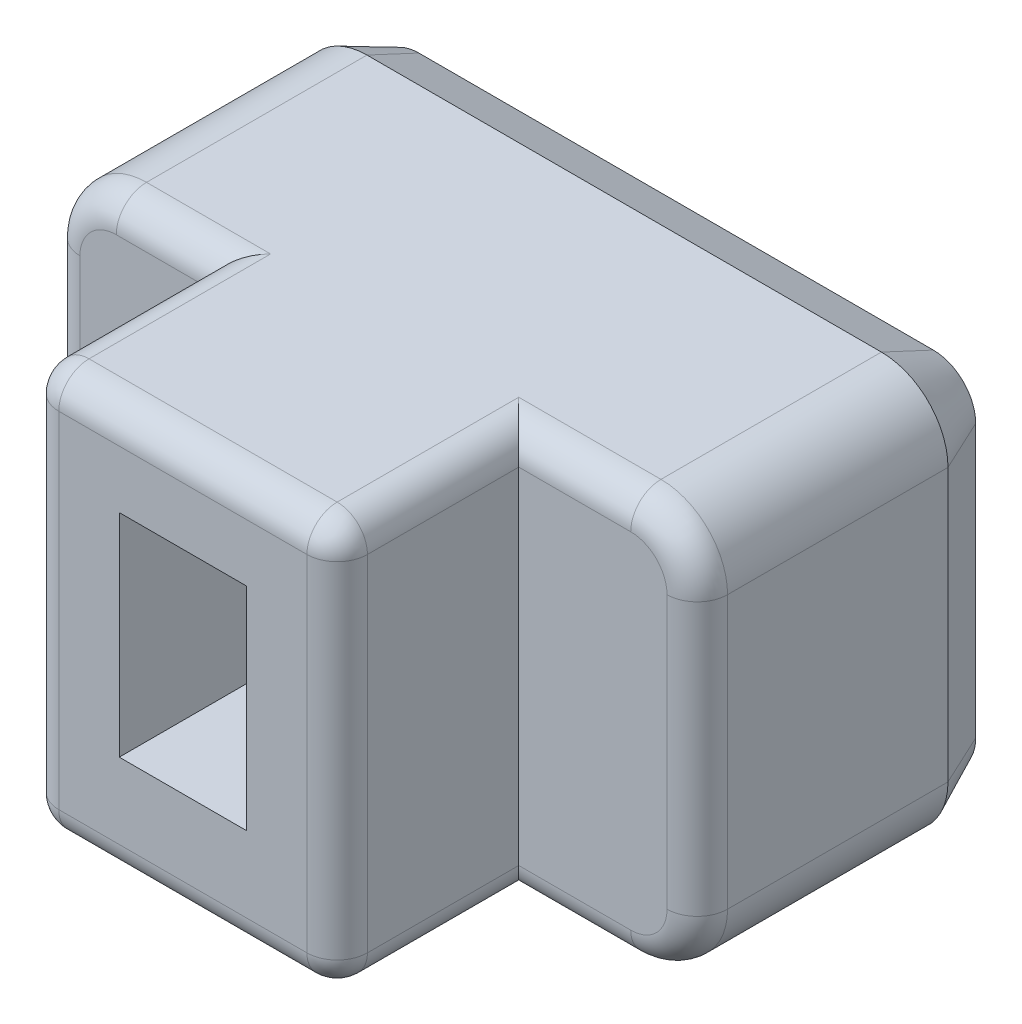
from build123d import *

# Parameters (mm, degrees)
BOSS_EXTRU_1_DEPTH      = 8
ESQUISSE3_W             = 2.1
ESQUISSE3_H             = 3.5
ENL_V_MAT_EXTRU_1_DEPTH = 3
ESQUISSE4_OUTSIDE_W     = 15.69
ESQUISSE4_OUTSIDE_H     = 11.69
ESQUISSE4_OUTSIDE_W_2   = 5.1
ESQUISSE4_OUTSIDE_H_2   = 6.7
ENL_V_MAT_EXTRU_2_DEPTH = 3
CONG_1_R                = 0.5
CHANFREIN1_SIZE         = 0.4
CHANFREIN1_SIZE2        = 0.857802768
ENL_V_MAT_EXTRU_3_DEPTH = 0.2
BOSS_EXTRU_2_DEPTH      = 0.2
BOSS_EXTRU_2_2_DEPTH    = 0.2
BOSS_EXTRU_2_3_DEPTH    = 0.2


with BuildPart() as part:
    # Esquisse2 → Boss.-Extru.1 (new body)
    with BuildSketch(Plane.XY):
        with BuildLine():
            Line((1.1, 0), (9.6, 0))
            ThreePointArc((9.6, 0), (10.377817459, 0.322182541), (10.7, 1.1))
            Line((10.7, 1.1), (10.7, 5.6))
            ThreePointArc((10.7, 5.6), (10.377817459, 6.377817459), (9.6, 6.7))
            Line((9.6, 6.7), (1.1, 6.7))
            ThreePointArc((1.1, 6.7), (0.322182541, 6.377817459), (0, 5.6))
            Line((0, 5.6), (0, 1.1))
            ThreePointArc((0, 1.1), (0.322182541, 0.322182541), (1.1, 0))
        make_face()
    extrude(amount=BOSS_EXTRU_1_DEPTH)

    # Esquisse3 → Enlèv. mat.-Extru.1 (cut)
    with BuildSketch(Plane.XY.offset(8)):
        with Locations((5.2, 3.5)):
            Rectangle(ESQUISSE3_W, ESQUISSE3_H)
    extrude(amount=-ENL_V_MAT_EXTRU_1_DEPTH, mode=Mode.SUBTRACT)

    # Esquisse4 outside → Enlèv. mat.-Extru.2 (cut)
    with BuildSketch(Plane.XY.offset(8)):
        with Locations((5.35, 3.35)):
            Rectangle(ESQUISSE4_OUTSIDE_W, ESQUISSE4_OUTSIDE_H)
        with Locations((5.2, 3.35)):
            Rectangle(ESQUISSE4_OUTSIDE_W_2, ESQUISSE4_OUTSIDE_H_2, mode=Mode.SUBTRACT)
    extrude(amount=-ENL_V_MAT_EXTRU_2_DEPTH, mode=Mode.SUBTRACT)

    # Congé1
    cong_1_edges = [part.edges().sort_by_distance(p)[0] for p in [
        (8.675, 0, 5),
        (10.377817459, 0.322182541, 5),
        (10.7, 3.35, 5),
        (10.377817459, 6.377817459, 5),
        (1.875, 6.7, 5),
        (0.322182541, 6.377817459, 5),
        (1.875, 0, 5),
        (0.322182541, 0.322182541, 5),
        (7.75, 6.7, 6.5),
        (2.65, 6.7, 6.5),
        (7.75, 0, 6.5),
        (2.65, 0, 6.5),
        (2.65, 3.35, 8),
        (5.2, 6.7, 8),
        (7.75, 3.35, 8),
        (5.2, 0, 8),
        (8.675, 6.7, 5),
        (0, 3.35, 5),
    ]]
    fillet(cong_1_edges, radius=CONG_1_R)

    # Chanfrein1
    chanfrein1_edges = [part.edges().sort_by_distance(p)[0] for p in [
        (5.35, 0, 0),
        (10.377817459, 0.322182541, 0),
        (0.322182541, 0.322182541, 0),
        (10.7, 3.35, 0),
        (0, 3.35, 0),
        (10.377817459, 6.377817459, 0),
        (0.322182541, 6.377817459, 0),
        (5.35, 6.7, 0),
    ]]
    chanfrein1_side = [part.faces().sort_by_distance(p)[0] for p in [
        (5.35, 3.35, 0),
    ]]
    chamfer(chanfrein1_edges, length=CHANFREIN1_SIZE, length2=CHANFREIN1_SIZE2, reference=chanfrein1_side[0])

    # Esquisse5 → Enlèv. mat.-Extru.3 (cut)
    with BuildSketch(Plane.XY):
        Polygon((2.11844453, 4.708587918), (3.713440101, 4.708587918), (3.713440101, 5.092998901), (1.739458701, 5.092998901), (1.739458701, 1.592998901), (3.627412643, 1.592998901), (3.627412643, 1.977409884), (2.11844453, 1.977409884), (2.11844453, 3.107392169), (3.46000786, 3.107392169), (3.46000786, 3.491803153), (2.11844453, 3.491803153), align=None)
        with BuildLine():
            add(Edge.make_bspline(
                [(5.687886514, 3.544504658), (5.783379122, 3.700654457), (5.975874702, 4.015423806), (6.160061615, 4.33512635), (6.252877656, 4.49623185)],
                knots=[0, 0, 0, 0, 0.992153778, 2, 2, 2, 2], degree=3))
            Line((6.252877656, 4.49623185), (6.266828055, 4.49623185))
            add(Edge.make_bspline(
                [(6.266828055, 4.49623185), (6.258108677, 4.324471085), (6.240506943, 3.977739075), (6.237911785, 3.630569277), (6.236602191, 3.455377112)],
                knots=[0, 0, 0, 0, 0.990740747, 2, 2, 2, 2], degree=3))
            Line((6.236602191, 3.455377112), (6.236602191, 1.592998901))
            Line((6.236602191, 1.592998901), (6.615588019, 1.592998901))
            Line((6.615588019, 1.592998901), (6.615588019, 5.092998901))
            Line((6.615588019, 5.092998901), (6.238927258, 5.092998901))
            Line((6.238927258, 5.092998901), (5.018267382, 3.141493144))
            add(Edge.make_bspline(
                [(5.018267382, 3.141493144), (4.966567896, 3.058224881), (4.865182286, 2.894931114), (4.721122886, 2.652016731), (4.583012533, 2.418899666), (4.495920572, 2.265082227), (4.453276239, 2.189765951)],
                knots=[0, 0, 0, 0, 1.062550423, 2.083721383, 3.06169958, 4, 4, 4, 4], degree=3))
            Line((4.453276239, 2.189765951), (4.439325841, 2.189765951))
            add(Edge.make_bspline(
                [(4.439325841, 2.189765951), (4.444061402, 2.27267783), (4.453926705, 2.445403045), (4.462318939, 2.714672702), (4.469221198, 3.004020303), (4.469439097, 3.20348993), (4.469551704, 3.30657286)],
                knots=[0, 0, 0, 0, 0.891833965, 1.85790283, 2.892996115, 4, 4, 4, 4], degree=3))
            Line((4.469551704, 3.30657286), (4.469551704, 5.092998901))
            Line((4.469551704, 5.092998901), (4.090565876, 5.092998901))
            Line((4.090565876, 5.092998901), (4.090565876, 1.592998901))
            Line((4.090565876, 1.592998901), (4.467226638, 1.592998901))
            Line((4.467226638, 1.592998901), (5.687886514, 3.544504658))
        make_face()
        Polygon((8.252124778, 5.092998901), (7.873138949, 5.092998901), (7.873138949, 1.977409884), (6.833834255, 1.977409884), (6.833834255, 1.592998901), (9.291429472, 1.592998901), (9.291429472, 1.977409884), (8.252124778, 1.977409884), align=None)
    extrude(amount=ENL_V_MAT_EXTRU_3_DEPTH, mode=Mode.SUBTRACT)


with BuildPart() as body_2:
    # Esquisse5_4 → Boss.-Extru.2 (new body)
    with BuildSketch(Plane.XY):
        Polygon((2.11844453, 4.708587918), (3.713440101, 4.708587918), (3.713440101, 5.092998901), (1.739458701, 5.092998901), (1.739458701, 1.592998901), (3.627412643, 1.592998901), (3.627412643, 1.977409884), (2.11844453, 1.977409884), (2.11844453, 3.107392169), (3.46000786, 3.107392169), (3.46000786, 3.491803153), (2.11844453, 3.491803153), align=None)
    extrude(amount=-BOSS_EXTRU_2_DEPTH)


with BuildPart() as body_3:
    # Esquisse5_4 → Boss.-Extru.2 2 (new body)
    with BuildSketch(Plane.XY):
        with BuildLine():
            add(Edge.make_bspline(
                [(5.687886514, 3.544504658), (5.783379122, 3.700654457), (5.975874702, 4.015423806), (6.160061615, 4.33512635), (6.252877656, 4.49623185)],
                knots=[0, 0, 0, 0, 0.992153778, 2, 2, 2, 2], degree=3))
            Line((6.252877656, 4.49623185), (6.266828055, 4.49623185))
            add(Edge.make_bspline(
                [(6.266828055, 4.49623185), (6.258108677, 4.324471085), (6.240506943, 3.977739075), (6.237911785, 3.630569277), (6.236602191, 3.455377112)],
                knots=[0, 0, 0, 0, 0.990740747, 2, 2, 2, 2], degree=3))
            Line((6.236602191, 3.455377112), (6.236602191, 1.592998901))
            Line((6.236602191, 1.592998901), (6.615588019, 1.592998901))
            Line((6.615588019, 1.592998901), (6.615588019, 5.092998901))
            Line((6.615588019, 5.092998901), (6.238927258, 5.092998901))
            Line((6.238927258, 5.092998901), (5.018267382, 3.141493144))
            add(Edge.make_bspline(
                [(5.018267382, 3.141493144), (4.966567896, 3.058224881), (4.865182286, 2.894931114), (4.721122886, 2.652016731), (4.583012533, 2.418899666), (4.495920572, 2.265082227), (4.453276239, 2.189765951)],
                knots=[0, 0, 0, 0, 1.062550423, 2.083721383, 3.06169958, 4, 4, 4, 4], degree=3))
            Line((4.453276239, 2.189765951), (4.439325841, 2.189765951))
            add(Edge.make_bspline(
                [(4.439325841, 2.189765951), (4.444061402, 2.27267783), (4.453926705, 2.445403045), (4.462318939, 2.714672702), (4.469221198, 3.004020303), (4.469439097, 3.20348993), (4.469551704, 3.30657286)],
                knots=[0, 0, 0, 0, 0.891833965, 1.85790283, 2.892996115, 4, 4, 4, 4], degree=3))
            Line((4.469551704, 3.30657286), (4.469551704, 5.092998901))
            Line((4.469551704, 5.092998901), (4.090565876, 5.092998901))
            Line((4.090565876, 5.092998901), (4.090565876, 1.592998901))
            Line((4.090565876, 1.592998901), (4.467226638, 1.592998901))
            Line((4.467226638, 1.592998901), (5.687886514, 3.544504658))
        make_face()
    extrude(amount=-BOSS_EXTRU_2_2_DEPTH)


with BuildPart() as body_4:
    # Esquisse5_4 → Boss.-Extru.2 3 (new body)
    with BuildSketch(Plane.XY):
        Polygon((8.252124778, 5.092998901), (7.873138949, 5.092998901), (7.873138949, 1.977409884), (6.833834255, 1.977409884), (6.833834255, 1.592998901), (9.291429472, 1.592998901), (9.291429472, 1.977409884), (8.252124778, 1.977409884), align=None)
    extrude(amount=-BOSS_EXTRU_2_3_DEPTH)


solid = Compound([part.part, body_2.part, body_3.part, body_4.part])
